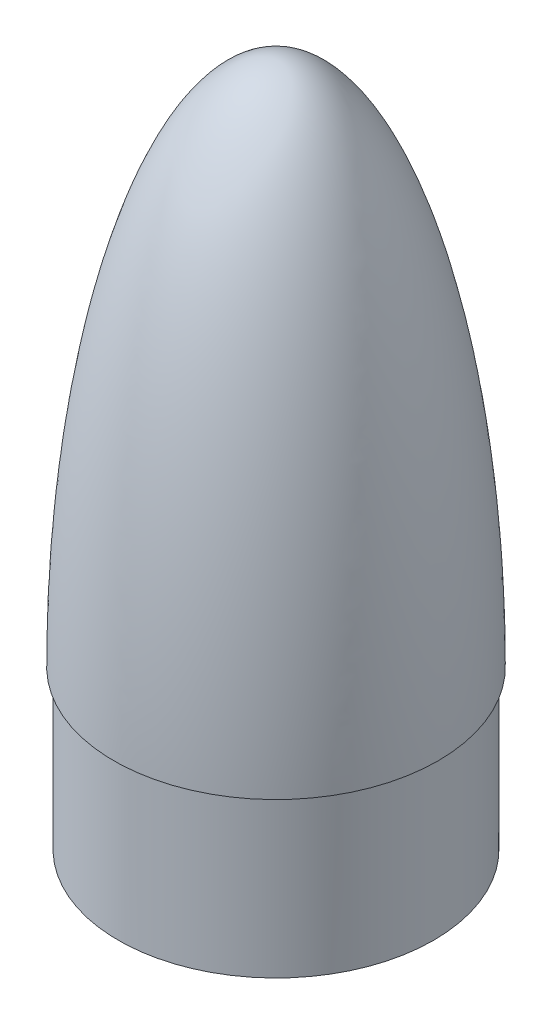
from build123d import *

# Parameters (mm, degrees)
SKETCH2_R           = 76.2
BOSS_EXTRUDE1_DEPTH = 76.2


with BuildPart() as part:
    # Sketch1 → Revolve1 (revolve)
    with BuildSketch(Plane.XY):
        with BuildLine():
            Line((78.359, 0), (0, 0))
            Line((0, 0), (0, 254))
            add(Edge.make_bspline(
                [(78.359, 0), (78.359, 0.547287489), (78.357845602, 1.649563618), (78.352650776, 3.586349875), (78.338796346, 5.988934596), (78.318010672, 8.352211569), (78.29028895, 10.745600888), (78.246958697, 13.731411826), (78.181061307, 17.311703382), (78.08386626, 21.490442467), (77.944822085, 26.264117007), (77.777683186, 31.037557631), (77.58229134, 35.809557456), (77.358460439, 40.580511863), (77.042853487, 46.542286246), (76.679080298, 52.501436144), (76.266448568, 58.457359127), (75.804102806, 64.409607399), (75.404015228, 69.168949637), (74.865626928, 75.114798701), (74.157385744, 82.243973993), (73.238266918, 90.551730955), (72.055740597, 100.030771811), (70.735528943, 109.491671534), (69.270929118, 118.931305028), (67.249996919, 130.699881306), (64.501732948, 144.763840427), (61.308555538, 158.735984092), (57.591049496, 172.577213574), (53.383025938, 186.275905479), (49.238746312, 198.044837449), (44.48323743, 209.587335711), (38.942884235, 220.71924179), (34.256173135, 228.693595393), (29.818710248, 235.095423042), (25.624249732, 240.182852143), (21.978892835, 243.926180276), (18.570150197, 246.859542723), (15.474349081, 249.076247661), (12.563405711, 250.785701438), (9.772327363, 252.08353387), (7.063069709, 253.028642362), (4.275373805, 253.686778481), (2.188006886, 253.939891173), (0.767171586, 253.999916555), (0, 254)],
                knots=[0.083290168, 0.083290168, 0.083290168, 0.083290168, 0.083290168, 0.091119674, 0.09894918, 0.106778686, 0.114608192, 0.122437698, 0.130267203, 0.145926215, 0.161585227, 0.177244239, 0.192903251, 0.208562263, 0.224221275, 0.239880287, 0.27119831, 0.286857322, 0.302516334, 0.318175346, 0.333834359, 0.365152383, 0.396470407, 0.42778843, 0.459106453, 0.490424474, 0.521742495, 0.584378539, 0.647014581, 0.678332609, 0.709650637, 0.772286631, 0.810589211, 0.841907031, 0.872607503, 0.893486158, 0.91262845, 0.928287274, 0.941044948, 0.952387223, 0.962498308, 0.97249612, 0.981348672, 0.989949856, 1, 1, 1, 1, 1], degree=4))
        make_face()
    revolve(axis=Axis((0, 254, 0), (0, -1, 0)))

    # Sketch2 → Boss-Extrude1 (add)
    with BuildSketch(Plane.XZ):
        Circle(SKETCH2_R)
    extrude(amount=BOSS_EXTRUDE1_DEPTH)


solid = part.part
